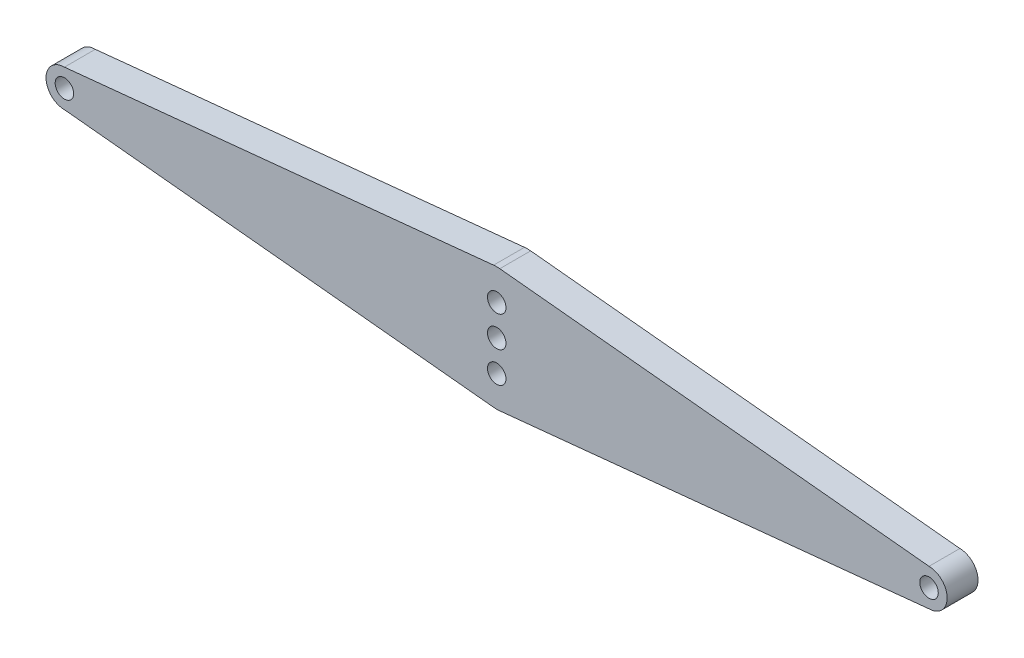
from build123d import *

# Parameters (mm, degrees)
SKETCH_1_R      = 0.3
EXTRUDE_4_DEPTH = 1


with BuildPart() as part:
    # 草图1 → 凸台-拉伸4 (new body)
    with BuildSketch(Plane.XY):
        with BuildLine():
            Line((-0.100008903, 1.994986542), (-14.006783195, 0.597177449))
            ThreePointArc((-14.006783195, 0.597177449), (-14.603960644, 0), (-14.006783195, -0.597177449))
            Line((-14.006783195, -0.597177449), (-0.100008903, -1.994986542))
            ThreePointArc((-0.100008903, -1.994986542), (0, -2), (0.100008903, -1.994986542))
            Line((0.100008903, -1.994986542), (14.006783195, -0.597177449))
            ThreePointArc((14.006783195, -0.597177449), (14.595169998, 0), (14.006783195, 0.597177449))
            Line((14.006783195, 0.597177449), (0.100008903, 1.994986542))
            ThreePointArc((0.100008903, 1.994986542), (0, 2), (-0.100008903, 1.994986542))
        make_face()
        with Locations((0, -1)):
            Circle(SKETCH_1_R, mode=Mode.SUBTRACT)
        with Locations((-14.006783195, 0)):
            Circle(SKETCH_1_R, mode=Mode.SUBTRACT)
        with BuildLine():
            ThreePointArc((0, -0.3), (-0.3, 0), (0, 0.3))
            ThreePointArc((0, 0.3), (0.3, 0), (0, -0.3))
        make_face(mode=Mode.SUBTRACT)
        with Locations((0, 1)):
            Circle(SKETCH_1_R, mode=Mode.SUBTRACT)
        with Locations((14.006783195, 0)):
            Circle(SKETCH_1_R, mode=Mode.SUBTRACT)
    extrude(amount=EXTRUDE_4_DEPTH)


solid = part.part
